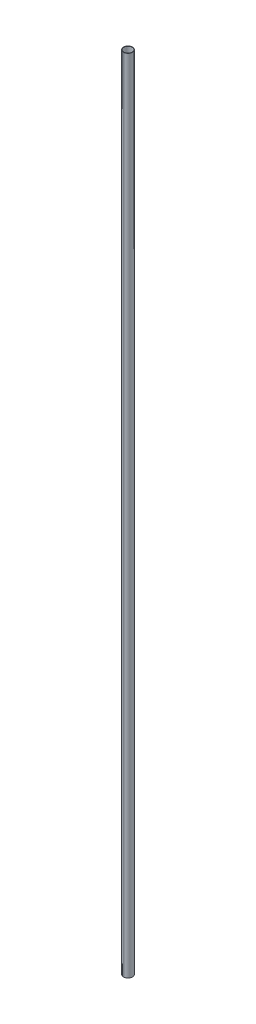
from build123d import *

# Parameters (mm, degrees)
SKETCH1_R           = 13.716
SKETCH1_R_2         = 12.7
BOSS_EXTRUDE1_DEPTH = 2438.4


with BuildPart() as part:
    # Sketch1 → Boss-Extrude1 (new body)
    with BuildSketch(Plane(origin=(0, 0, 0), x_dir=(1, 0, 0), z_dir=(0, 1, 0))):
        Circle(SKETCH1_R)
        Circle(SKETCH1_R_2, mode=Mode.SUBTRACT)
    extrude(amount=BOSS_EXTRUDE1_DEPTH)


solid = part.part
